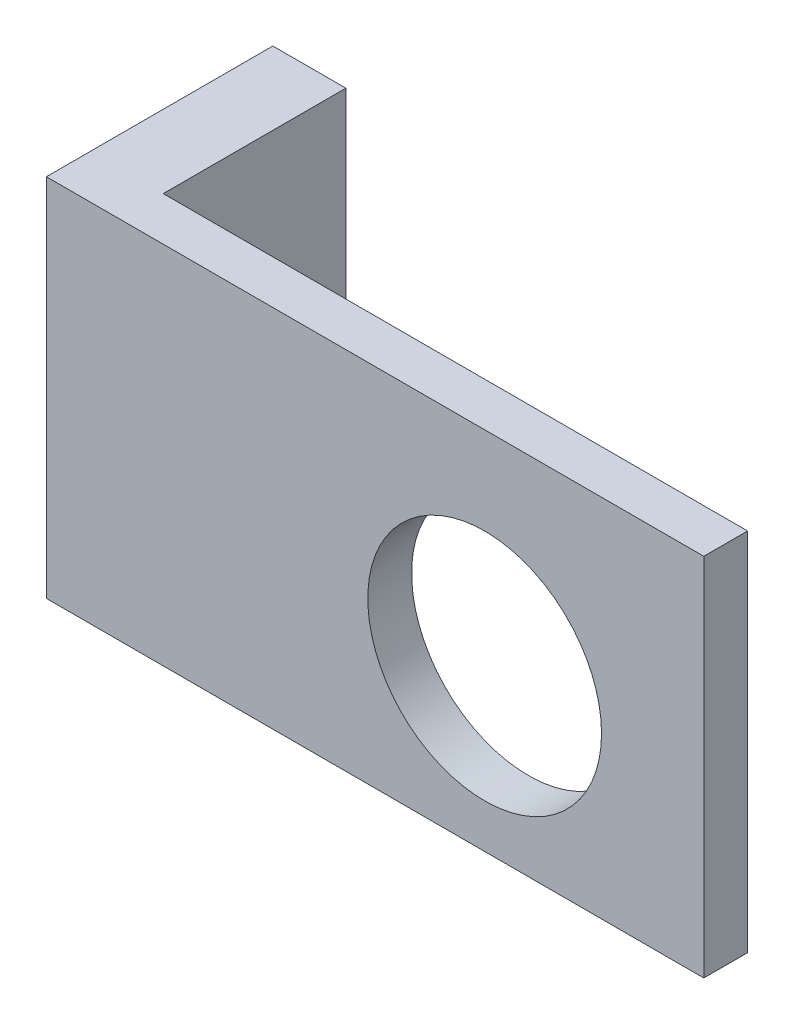
from build123d import *

# Parameters (mm, degrees)
SKETCH1_W           = 90
SKETCH1_H           = 50
SKETCH1_R           = 16
BOSS_EXTRUDE1_DEPTH = 6
SKETCH3_W           = 10
SKETCH3_H           = 50
BOSS_EXTRUDE2_DEPTH = 25
SCALE1_SCALE        = 7.5


with BuildPart() as part:
    # Sketch1 → Boss-Extrude1 (new body)
    with BuildSketch(Plane.XY):
        with Locations((45, 25)):
            Rectangle(SKETCH1_W, SKETCH1_H)
        with Locations((60, 22)):
            Circle(SKETCH1_R, mode=Mode.SUBTRACT)
    extrude(amount=BOSS_EXTRUDE1_DEPTH)

    # Sketch3 → Boss-Extrude2 (add)
    with BuildSketch(Plane(origin=(0, 0, 0), x_dir=(-1, 0, 0), z_dir=(0, 0, -1))):
        with Locations((-5, 25)):
            Rectangle(SKETCH3_W, SKETCH3_H)
    extrude(amount=BOSS_EXTRUDE2_DEPTH)


with BuildPart() as part_1:
    # Scale1: scaled about (28.492708796, 25.417495659, -2.587677502)
    add(part.part.scale(SCALE1_SCALE).moved(Location((-185.202607174, -165.213721784, 16.819903763))))


solid = part_1.part
